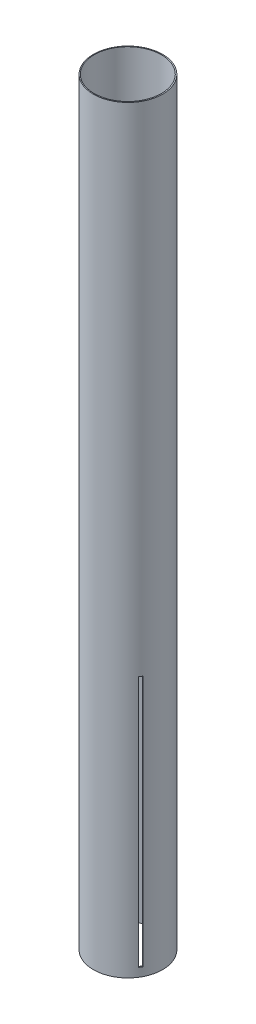
from build123d import *

# Parameters (mm, degrees)
SKETCH1_R           = 51
SKETCH1_R_2         = 49.55
BOSS_EXTRUDE1_DEPTH = 1117.6
CUT_EXTRUDE1_DEPTH  = 52
CIRPATTERN1_COUNT   = 3


with BuildPart() as part:
    # Sketch1 → Boss-Extrude1 (new body)
    with BuildSketch(Plane(origin=(0, 0, 0), x_dir=(1, 0, 0), z_dir=(0, 1, 0))):
        Circle(SKETCH1_R)
        with Locations((-0.342312985, 0)):
            Circle(SKETCH1_R_2, mode=Mode.SUBTRACT)
    extrude(amount=BOSS_EXTRUDE1_DEPTH)

    # Sketch2 → Cut-Extrude1 (cut, through all)
    with BuildSketch(Plane.XY):
        Polygon((0, 12.7), (2.38, 12.7), (2.38, 383.7), (-2.38, 383.7), (-2.38, 12.7), align=None)
    cut_extrude1 = extrude(amount=-CUT_EXTRUDE1_DEPTH, mode=Mode.SUBTRACT)

    # CirPattern1: Cut-Extrude1 ×3 about axis
    cirpattern1_axis = Axis((0, 0, 0), (0, 1, 0))
    for i in range(1, CIRPATTERN1_COUNT):
        add(cut_extrude1.rotate(cirpattern1_axis, i * 360 / CIRPATTERN1_COUNT), mode=Mode.SUBTRACT)


solid = part.part
